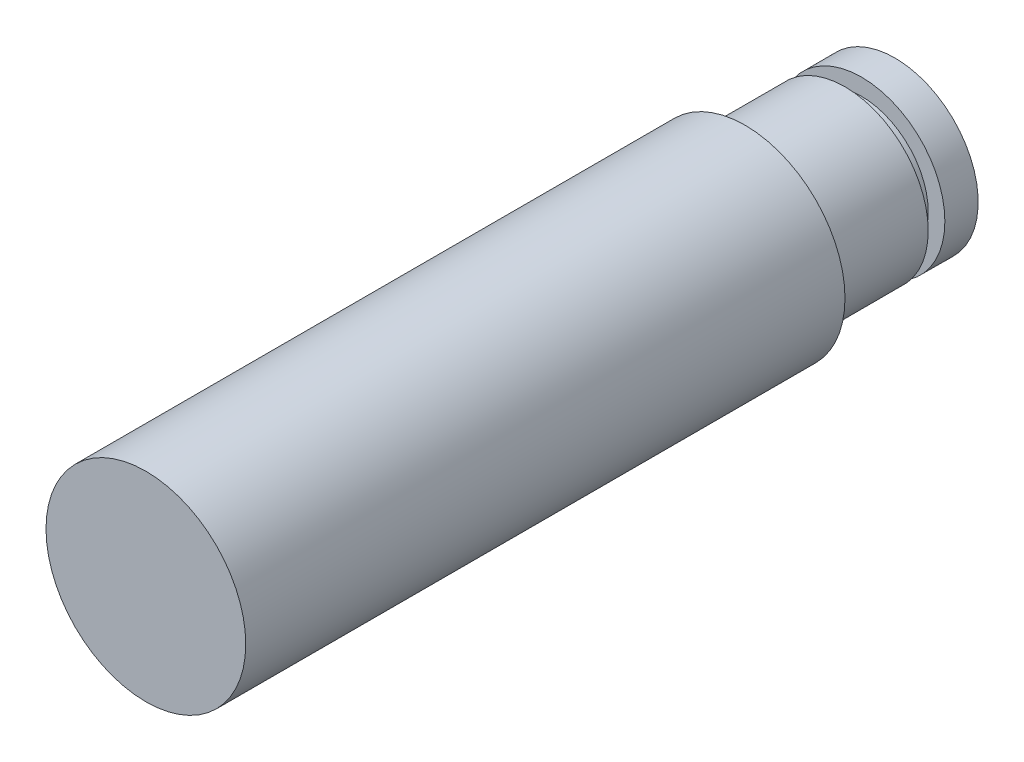
from build123d import *

# Parameters (mm, degrees)
SKETCH1_R           = 12
BOSS_EXTRUDE1_DEPTH = 90
SKETCH2_R           = 12
SKETCH2_R_2         = 10
CUT_EXTRUDE2_DEPTH  = 18
SKETCH3_W           = 2
SKETCH3_H           = 2


with BuildPart() as part:
    # Sketch1 → Boss-Extrude1 (new body)
    with BuildSketch(Plane.XY):
        Circle(SKETCH1_R)
    extrude(amount=BOSS_EXTRUDE1_DEPTH)

    # Sketch2 → Cut-Extrude2 (cut)
    with BuildSketch(Plane(origin=(0, 0, 0), x_dir=(-1, 0, 0), z_dir=(0, 0, -1))):
        Circle(SKETCH2_R)
        Circle(SKETCH2_R_2, mode=Mode.SUBTRACT)
    extrude(amount=-CUT_EXTRUDE2_DEPTH, mode=Mode.SUBTRACT)

    # Sketch3 → Cut-Revolve1 (revolve, cut)
    with BuildSketch(Plane(origin=(0, 0, 0), x_dir=(0, 0, -1), z_dir=(1, 0, 0))):
        with Locations((-5, 9)):
            Rectangle(SKETCH3_W, SKETCH3_H)
    revolve(axis=Axis((0, 0, 18), (0, 0, -1)), mode=Mode.SUBTRACT)


solid = part.part
